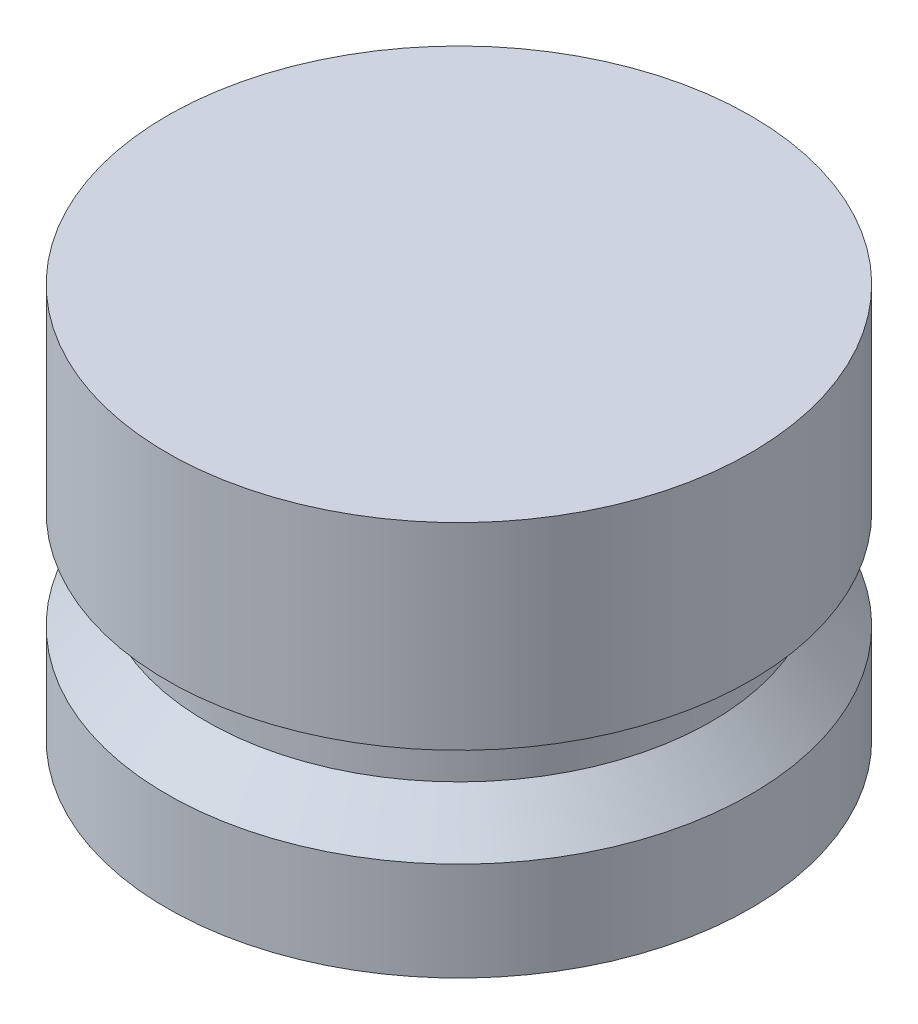
from build123d import *


with BuildPart() as part:
    # Sketch1 → Revolve1 (revolve)
    with BuildSketch(Plane.XY):
        Polygon((0, 0), (-9.398, 0), (-9.398, 3.175), (-8.128, 4.572), (-8.128, 6.35), (-9.398, 6.35), (-9.398, 12.7), (0, 12.7), align=None)
    revolve(axis=Axis((0, 0, 0), (0, 1, 0)))


solid = part.part
